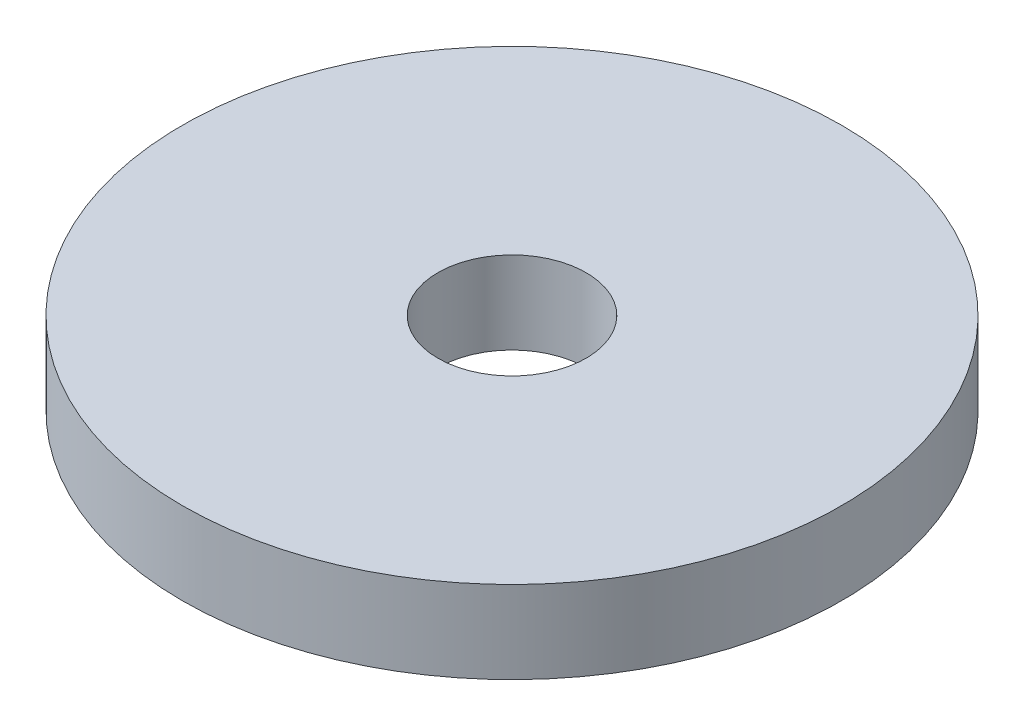
from build123d import *

# Parameters (mm, degrees)
SKETCH1_R           = 20
SKETCH1_R_2         = 4.5
BOSS_EXTRUDE1_DEPTH = 5


with BuildPart() as part:
    # Sketch1 → Boss-Extrude1 (new body)
    with BuildSketch(Plane(origin=(0, 0, 0), x_dir=(1, 0, 0), z_dir=(0, 1, 0))):
        with Locations(Location((0, 0, 0), (0, 0, 270))):  # turned: the seam where the file's is
            Circle(SKETCH1_R)
        with Locations(Location((0, 0, 0), (0, 0, 270))):  # turned: the seam where the file's is
            Circle(SKETCH1_R_2, mode=Mode.SUBTRACT)
    extrude(amount=-BOSS_EXTRUDE1_DEPTH)


solid = part.part
